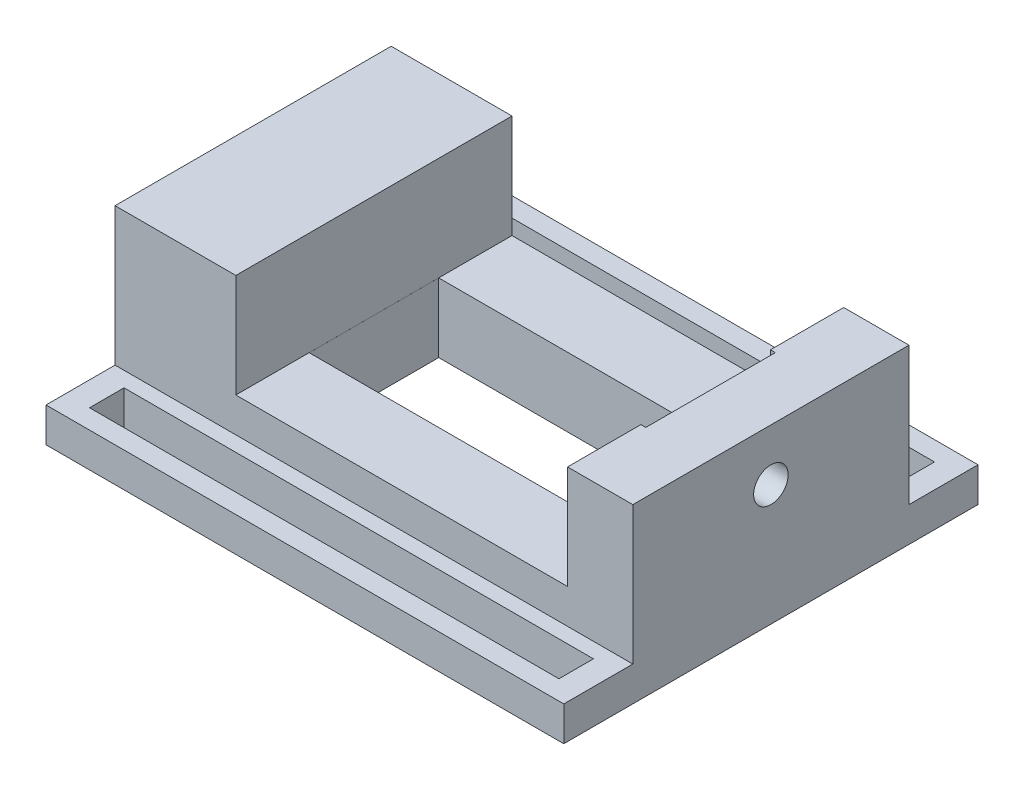
from build123d import *

# Parameters (mm, degrees)
SKETCH_1_W          = 150
SKETCH_1_H          = 80
EXTRUDE_1_DEPTH     = 40
SKETCH_2_W          = 150
SKETCH_2_H          = 120
SKETCH_2_W_2        = 135.983002124
SKETCH_2_H_2        = 10
EXTRUDE_2_DEPTH     = 10
SKETCH_3_W          = 96.092988376
SKETCH_3_H          = 30
CUT_EXTRUDE_1_DEPTH = 101
SKETCH_5_W          = 97.510223457
SKETCH_5_H          = 37.534840072
CUT_EXTRUDE_2_DEPTH = 51
SKETCH_6_R          = 5
CUT_EXTRUDE_3_DEPTH = 30


with BuildPart() as part:
    # Эскиз1 → Бобышка-Вытянуть1 (new body)
    with BuildSketch(Plane(origin=(0, 0, 0), x_dir=(1, 0, 0), z_dir=(0, 1, 0))):
        Rectangle(SKETCH_1_W, SKETCH_1_H)
    extrude(amount=EXTRUDE_1_DEPTH)

    # Эскиз2 → Бобышка-Вытянуть2 (add)
    with BuildSketch(Plane.XZ):
        Rectangle(SKETCH_2_W, SKETCH_2_H)
        with Locations((0, 49.39320085)):
            Rectangle(SKETCH_2_W_2, SKETCH_2_H_2, mode=Mode.SUBTRACT)
        with Locations((0, -49.39320085)):
            Rectangle(SKETCH_2_W_2, SKETCH_2_H_2, mode=Mode.SUBTRACT)
    extrude(amount=EXTRUDE_2_DEPTH)

    # Эскиз3 → Вырез-Вытянуть1 (cut, through all)
    with BuildSketch(Plane.XY.offset(40)):
        with Locations((8.046494188, 25)):
            Rectangle(SKETCH_3_W, SKETCH_3_H)
    extrude(amount=-CUT_EXTRUDE_1_DEPTH, mode=Mode.SUBTRACT)

    # Эскиз5 → Вырез-Вытянуть2 (cut, through all)
    with BuildSketch(Plane.XZ.offset(10)):
        with Locations((8.760111104, 0)):
            Rectangle(SKETCH_5_W, SKETCH_5_H)
    extrude(amount=-CUT_EXTRUDE_2_DEPTH, mode=Mode.SUBTRACT)

    # Эскиз6 → Вырез-Вытянуть3 (cut)
    with BuildSketch(Plane(origin=(75, 0, 0), x_dir=(0, 0, -1), z_dir=(1, 0, 0))):
        with Locations((0, 25)):
            Circle(SKETCH_6_R)
    extrude(amount=-CUT_EXTRUDE_3_DEPTH, mode=Mode.SUBTRACT)


solid = part.part
